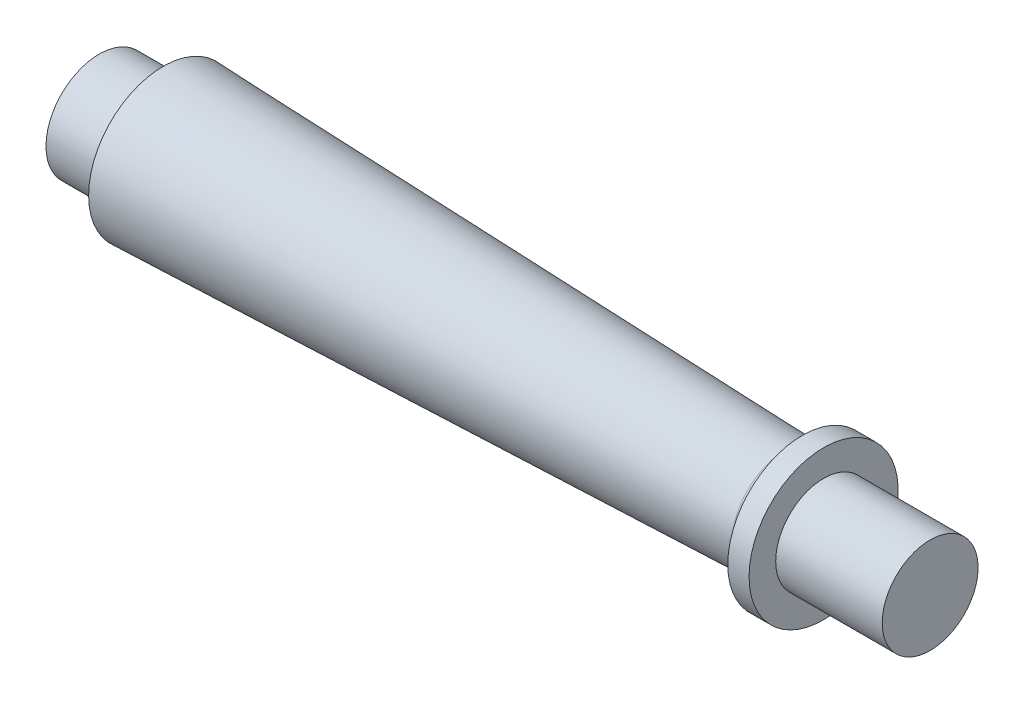
from build123d import *

# Parameters (mm, degrees)
FILLET1_R = 1.5


with BuildPart() as part:
    # Sketch1 → Revolve1 (revolve)
    with BuildSketch(Plane.XY):
        Polygon((0, 0), (78, 0), (78, 4.5), (68, 4.5), (68, 7), (66, 7), (66, 5), (6, 7), (6, 5), (0, 5), align=None)
    revolve(axis=Axis((0, 0, 0), (1, 0, 0)))

    # Fillet1
    fillet1_edges = [part.edges().sort_by_distance(p)[0] for p in [
        (66, -5, 0),
    ]]
    fillet(fillet1_edges, radius=FILLET1_R)


solid = part.part
